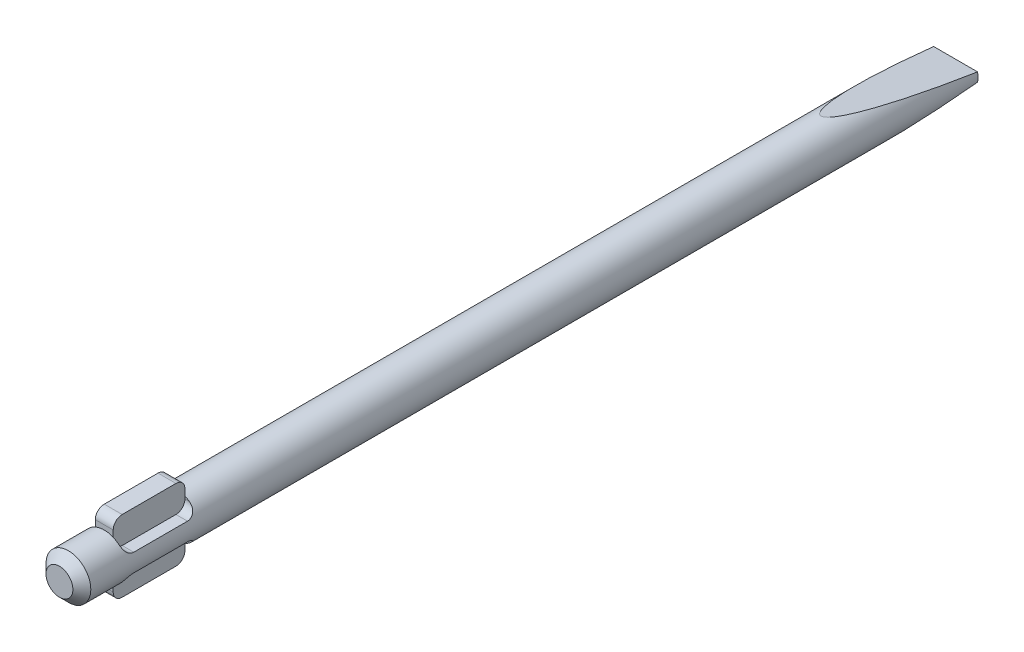
from build123d import *

# Parameters (mm, degrees)
SKETCH1_R               = 2.5
BOSS_EXTRUDE1_DEPTH     = 100
CUT_EXTRUDE1_DEPTH      = 5
BOSS_EXTRUDE2_DEPTH     = 1
CHAMFER1_SIZE           = 1
CUT_EXTRUDE2_DEPTH      = 101.111188188
CUT_EXTRUDE2_DEPTH_BACK = 101.111188188


with BuildPart() as part:
    # Sketch1 → Boss-Extrude1 (new body)
    with BuildSketch(Plane.XY):
        Circle(SKETCH1_R)
    extrude(amount=BOSS_EXTRUDE1_DEPTH)

    # Sketch2 → Cut-Extrude1 (cut, symmetric)
    with BuildSketch(Plane(origin=(0, 0, 0), x_dir=(0, 0, -1), z_dir=(1, 0, 0))):
        with BuildLine():
            Line((-94, 4), (-88, 4))
            ThreePointArc((-88, 4), (-87.292893219, 3.707106781), (-87, 3))
            Line((-87, 3), (-87, 2))
            ThreePointArc((-87, 2), (-87.292893219, 1.292893219), (-88, 1))
            Line((-88, 1), (-94, 1))
            ThreePointArc((-94, 1), (-94.707106781, 1.292893219), (-95, 2))
            Line((-95, 2), (-95, 3))
            ThreePointArc((-95, 3), (-94.707106781, 3.707106781), (-94, 4))
        make_face()
        with BuildLine():
            Line((-87, -3), (-87, -2))
            ThreePointArc((-87, -2), (-87.292893219, -1.292893219), (-88, -1))
            Line((-88, -1), (-94, -1))
            ThreePointArc((-94, -1), (-94.707106781, -1.292893219), (-95, -2))
            Line((-95, -2), (-95, -3))
            ThreePointArc((-95, -3), (-94.707106781, -3.707106781), (-94, -4))
            Line((-94, -4), (-88, -4))
            ThreePointArc((-88, -4), (-87.292893219, -3.707106781), (-87, -3))
        make_face()
    extrude(amount=CUT_EXTRUDE1_DEPTH, both=True, mode=Mode.SUBTRACT)

    # Sketch2_2 → Boss-Extrude2 (add, symmetric)
    with BuildSketch(Plane(origin=(0, 0, 0), x_dir=(0, 0, -1), z_dir=(1, 0, 0))):
        with BuildLine():
            Line((-94, 4), (-88, 4))
            ThreePointArc((-88, 4), (-87.292893219, 3.707106781), (-87, 3))
            Line((-87, 3), (-87, 2))
            ThreePointArc((-87, 2), (-87.292893219, 1.292893219), (-88, 1))
            Line((-88, 1), (-94, 1))
            ThreePointArc((-94, 1), (-94.707106781, 1.292893219), (-95, 2))
            Line((-95, 2), (-95, 3))
            ThreePointArc((-95, 3), (-94.707106781, 3.707106781), (-94, 4))
        make_face()
        with BuildLine():
            Line((-87, -3), (-87, -2))
            ThreePointArc((-87, -2), (-87.292893219, -1.292893219), (-88, -1))
            Line((-88, -1), (-94, -1))
            ThreePointArc((-94, -1), (-94.707106781, -1.292893219), (-95, -2))
            Line((-95, -2), (-95, -3))
            ThreePointArc((-95, -3), (-94.707106781, -3.707106781), (-94, -4))
            Line((-94, -4), (-88, -4))
            ThreePointArc((-88, -4), (-87.292893219, -3.707106781), (-87, -3))
        make_face()
    extrude(amount=BOSS_EXTRUDE2_DEPTH, both=True)

    # Chamfer1
    chamfer1_edges = [part.edges().sort_by_distance(p)[0] for p in [
        (-2.5, 0, 100),
    ]]
    chamfer(chamfer1_edges, length=CHAMFER1_SIZE)

    # Sketch3 → Cut-Extrude2 (cut, two sides: drawn at the far end of the back side and taken through both)
    with BuildSketch(Plane(origin=(0, 0, 0), x_dir=(0, 0, -1), z_dir=(1, 0, 0)).offset(-CUT_EXTRUDE2_DEPTH_BACK)):
        Polygon((0, -2.5), (0, -0.5), (-15, -2.5), align=None)
        Polygon((-15, 2.5), (0, 0.5), (0, 2.5), align=None)
    extrude(amount=CUT_EXTRUDE2_DEPTH + CUT_EXTRUDE2_DEPTH_BACK, mode=Mode.SUBTRACT)


solid = part.part
